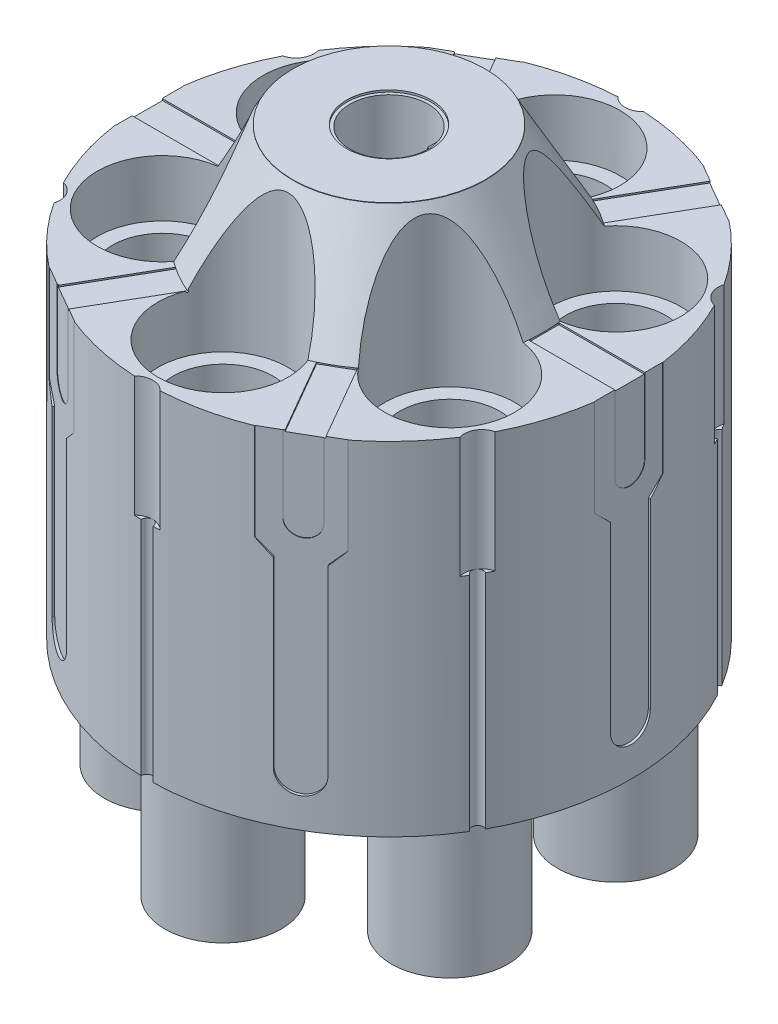
from build123d import *

# Parameters (mm, degrees)
SKETCH2_R            = 30.63
BOSS_EXTRUDE2_DEPTH  = 43.34
SKETCH6_R            = 19.45
BOSS_EXTRUDE6_DEPTH  = 13.09
SKETCH9_R            = 8.239204932
CUT_EXTRUDE1_DEPTH   = 20.25
SKETCH10_R           = 6.33
CUT_EXTRUDE2_DEPTH   = 37.18
SKETCH11_R           = 4.945
CUT_EXTRUDE3_DEPTH   = 35.4
SKETCH12_R           = 2.065
CUT_EXTRUDE4_DEPTH   = 22.03
SKETCH13_R           = 5.347056697
CUT_EXTRUDE5_DEPTH   = 0.25
BOSS_EXTRUDE7_DEPTH  = 34.5
SKETCH16_R           = 29.601532101
SKETCH16_R_2         = 7.36
SKETCH16_R_3         = 4.955
CUT_EXTRUDE9_DEPTH   = 34.5
SKETCH17_R           = 4.955
CUT_EXTRUDE12_DEPTH  = 14.38
SKETCH21_R           = 4.955
SKETCH21_R_2         = 3.15
CUT_EXTRUDE14_DEPTH  = 6.04
CUT_EXTRUDE15_DEPTH  = 0.2
SKETCH24_W           = 1.697473247
SKETCH24_H           = 3.797359521
CUT_EXTRUDE17_DEPTH  = 9.6
CUT_EXTRUDE18_DEPTH  = 0.4
CIRPATTERN1_COUNT    = 6
CUT_EXTRUDE19_DEPTH  = 0.35
CIRPATTERN2_COUNT    = 6
CUT_EXTRUDE23_DEPTH  = 44.3400001
CUT_EXTRUDE24_START  = 43.34
CUT_EXTRUDE24_DEPTH  = 15.26
CIRPATTERN3_COUNT    = 6
CIRPATTERN4_COUNT    = 6
SKETCH31_R           = 7.36
SKETCH31_R_2         = 6.33
BOSS_EXTRUDE10_DEPTH = 17.57


with BuildPart() as part:
    # Sketch2 → Boss-Extrude2 (new body)
    with BuildSketch(Plane(origin=(0, 0, 0), x_dir=(1, 0, 0), z_dir=(0, 1, 0))):
        Circle(SKETCH2_R)
    extrude(amount=BOSS_EXTRUDE2_DEPTH)

    # Sketch6 → Boss-Extrude6 (add)
    with BuildSketch(Plane(origin=(0, 43.34, 0), x_dir=(1, 0, 0), z_dir=(0, 1, 0))):
        Circle(SKETCH6_R)
    extrude(amount=BOSS_EXTRUDE6_DEPTH)

    # Sketch8 → Cut-Revolve5 (revolve, cut)
    with BuildSketch(Plane(origin=(0, 0, 0), x_dir=(0, 0, -1), z_dir=(1, 0, 0))):
        Polygon((19.45, 43.34), (19.45, 56.43), (19.45, 57.490398611), (12.16, 57.490398611), (12.16, 56.378913675), align=None)
    revolve(axis=Axis((0, 43.34, 0), (0, 1, 0)), mode=Mode.SUBTRACT)

    # Sketch9 → Cut-Extrude1 (cut)
    with BuildSketch(Plane(origin=(0, 56.43, 0), x_dir=(1, 0, 0), z_dir=(0, 1, 0))):
        with Locations((0, 20.994816625)):
            Circle(SKETCH9_R)
        with Locations((18.182044545, 10.497408313)):
            Circle(SKETCH9_R)
        with Locations((18.182044545, -10.497408313)):
            Circle(SKETCH9_R)
        with Locations((0, -20.994816625)):
            Circle(SKETCH9_R)
        with Locations((-18.182044545, -10.497408313)):
            Circle(SKETCH9_R)
        with Locations((-18.182044545, 10.497408313)):
            Circle(SKETCH9_R)
    extrude(amount=-CUT_EXTRUDE1_DEPTH, mode=Mode.SUBTRACT)

    # Sketch10 → Cut-Extrude2 (cut, through all)
    with BuildSketch(Plane(origin=(0, 36.18, 0), x_dir=(1, 0, 0), z_dir=(0, 1, 0))):
        with Locations((0, 20.994816625)):
            Circle(SKETCH10_R)
        with Locations((18.182044545, 10.497408313)):
            Circle(SKETCH10_R)
        with Locations((18.182044545, -10.497408313)):
            Circle(SKETCH10_R)
        with Locations((0, -20.994816625)):
            Circle(SKETCH10_R)
        with Locations((-18.182044545, -10.497408313)):
            Circle(SKETCH10_R)
        with Locations((-18.182044545, 10.497408313)):
            Circle(SKETCH10_R)
    extrude(amount=-CUT_EXTRUDE2_DEPTH, mode=Mode.SUBTRACT)

    # Sketch11 → Cut-Extrude3 (cut)
    with BuildSketch(Plane(origin=(0, 56.43, 0), x_dir=(1, 0, 0), z_dir=(0, 1, 0))):
        Circle(SKETCH11_R)
    extrude(amount=-CUT_EXTRUDE3_DEPTH, mode=Mode.SUBTRACT)

    # Sketch12 → Cut-Extrude4 (cut, through all)
    with BuildSketch(Plane(origin=(0, 21.03, 0), x_dir=(1, 0, 0), z_dir=(0, 1, 0))):
        Circle(SKETCH12_R)
    extrude(amount=-CUT_EXTRUDE4_DEPTH, mode=Mode.SUBTRACT)

    # Sketch13 → Cut-Extrude5 (cut)
    with BuildSketch(Plane(origin=(0, 56.43, 0), x_dir=(1, 0, 0), z_dir=(0, 1, 0))):
        Circle(SKETCH13_R)
    extrude(amount=-CUT_EXTRUDE5_DEPTH, mode=Mode.SUBTRACT)

    # Sketch15 → Boss-Extrude7 (add)
    with BuildSketch(Plane(origin=(0, 21.03, 0), x_dir=(1, 0, 0), z_dir=(0, 1, 0))):
        with BuildLine():
            Line((4.0682092, -2.811173937), (4.0682092, -0.81))
            Line((4.0682092, -0.81), (4.8782092, -0.81))
            ThreePointArc((4.8782092, -0.81), (4.583751174, -1.855330205), (4.0682092, -2.811173937))
        make_face()
        with BuildLine():
            Line((4.0682092, 2.811173937), (4.0682092, 0.81))
            Line((4.0682092, 0.81), (4.8782092, 0.81))
            ThreePointArc((4.8782092, 0.81), (4.583751174, 1.855330205), (4.0682092, 2.811173937))
        make_face()
    extrude(amount=BOSS_EXTRUDE7_DEPTH)

    # Sketch16 → Cut-Extrude9 (cut)
    with BuildSketch(Plane.XZ):
        Circle(SKETCH16_R)
        with Locations((-18.182044545, 10.497408313)):
            Circle(SKETCH16_R_2, mode=Mode.SUBTRACT)
        with Locations((0, 20.994816625)):
            Circle(SKETCH16_R_2, mode=Mode.SUBTRACT)
        with Locations((18.182044545, 10.497408313)):
            Circle(SKETCH16_R_2, mode=Mode.SUBTRACT)
        with Locations((18.182044545, -10.497408313)):
            Circle(SKETCH16_R_2, mode=Mode.SUBTRACT)
        with Locations((0, -20.994816625)):
            Circle(SKETCH16_R_2, mode=Mode.SUBTRACT)
        with Locations((-18.182044545, -10.497408313)):
            Circle(SKETCH16_R_2, mode=Mode.SUBTRACT)
        Circle(SKETCH16_R_3, mode=Mode.SUBTRACT)
    extrude(amount=-CUT_EXTRUDE9_DEPTH, mode=Mode.SUBTRACT)

    # Sketch17 → Cut-Extrude12 (cut)
    with BuildSketch(Plane(origin=(0, 0, 0), x_dir=(1, 0, 0), z_dir=(0, 1, 0))):
        Circle(SKETCH17_R)
    extrude(amount=CUT_EXTRUDE12_DEPTH, mode=Mode.SUBTRACT)

    # Sketch21 → Cut-Extrude14 (cut)
    with BuildSketch(Plane.XZ.offset(-14.38)):
        Circle(SKETCH21_R)
        Circle(SKETCH21_R_2, mode=Mode.SUBTRACT)
    extrude(amount=-CUT_EXTRUDE14_DEPTH, mode=Mode.SUBTRACT)

    # Sketch22 → Cut-Extrude15 (cut)
    with BuildSketch(Plane(origin=(0, 43.34, 0), x_dir=(1, 0, 0), z_dir=(0, 1, 0))):
        Polygon((7.938612136, 17.64626892), (16.01292294, 31.63138547), (19.268734276, 29.675897082), (11.227221947, 15.74758916), align=None)
        Polygon((19.408960881, 2.079443487), (19.408960881, -1.717916034), (35.491985537, -1.717916034), (35.55758249, 2.079443487), align=None)
        Polygon((11.662868972, -15.637582634), (8.37425916, -17.536262394), (16.415771488, -31.464570316), (19.737179776, -29.622699184), align=None)
        Polygon((-7.553571683, -17.787783321), (-10.842181495, -15.889103561), (-18.883693823, -29.817411483), (-15.627882487, -31.77289987), align=None)
        Polygon((-19.023920428, -2.220957887), (-19.023920428, 1.576401633), (-35.106945085, 1.576401633), (-35.172542037, -2.220957887), align=None)
        Polygon((-11.277828519, 15.496068233), (-7.989218707, 17.394747994), (-16.030731036, 31.323055916), (-19.352139324, 29.481184783), align=None)
    extrude(amount=-CUT_EXTRUDE15_DEPTH, mode=Mode.SUBTRACT)

    # Sketch24 → Cut-Extrude17 (cut)
    with BuildSketch(Plane(origin=(0, 43.34, 0), x_dir=(1, 0, 0), z_dir=(0, 1, 0))):
        with Locations((31.078736623, 0.180763727)):
            Rectangle(SKETCH24_W, SKETCH24_H)
        Polygon((17.764587509, -26.610281167), (16.915850885, -25.140226213), (13.627241073, -27.038905973), (14.475977697, -28.508960927), align=None)
        Polygon((-14.162885738, -28.689724654), (-13.314149115, -27.2196697), (-16.602758927, -25.32098994), (-17.45149555, -26.791044894), align=None)
        with Locations((-31.078736623, -0.180763727)):
            Rectangle(SKETCH24_W, SKETCH24_H)
        Polygon((-17.764587509, 26.610281167), (-16.915850885, 25.140226213), (-13.627241073, 27.038905973), (-14.475977697, 28.508960927), align=None)
        Polygon((14.162885738, 28.689724654), (13.314149115, 27.2196697), (16.602758927, 25.32098994), (17.45149555, 26.791044894), align=None)
    extrude(amount=-CUT_EXTRUDE17_DEPTH, mode=Mode.SUBTRACT)

    # Sketch26 → Cut-Extrude18 (cut)
    with BuildSketch(Plane(origin=(30.63, 0, 0), x_dir=(0, 0, -1), z_dir=(1, 0, 0))):
        with BuildLine():
            Line((-1.717916034, 33.74), (2.079443487, 33.74))
            ThreePointArc((2.079443487, 33.74), (0.180763726, 31.84132024), (-1.717916034, 33.74))
        make_face()
    cut_extrude18 = extrude(amount=-CUT_EXTRUDE18_DEPTH, mode=Mode.SUBTRACT)

    # CirPattern1: Cut-Extrude18 ×6 about axis
    cirpattern1_axis = Axis((0, 43.34, 0), (0, 1, 0))
    for i in range(1, CIRPATTERN1_COUNT):
        add(cut_extrude18.rotate(cirpattern1_axis, i * 360 / CIRPATTERN1_COUNT), mode=Mode.SUBTRACT)

    # Sketch28 → Cut-Extrude19 (cut)
    with BuildSketch(Plane(origin=(30.63, 0, 0), x_dir=(0, 0, -1), z_dir=(1, 0, 0))):
        with BuildLine():
            Line((-4.315, 44.053563196), (4.315, 44.053563196))
            Line((4.315, 44.053563196), (4.315, 31.142727483))
            Line((4.315, 31.142727483), (2.528620385, 29.356347868))
            Line((2.528620385, 29.356347868), (2.528620385, 6.318897274))
            ThreePointArc((2.528620385, 6.318897274), (0, 3.790276889), (-2.528620385, 6.318897274))
            Line((-2.528620385, 6.318897274), (-2.528620385, 29.356347868))
            Line((-2.528620385, 29.356347868), (-4.315, 31.142727483))
            Line((-4.315, 31.142727483), (-4.315, 44.053563196))
        make_face()
    cut_extrude19 = extrude(amount=-CUT_EXTRUDE19_DEPTH, mode=Mode.SUBTRACT)

    # CirPattern2: Cut-Extrude19 ×6 about axis
    cirpattern2_axis = Axis((0, 0, 0), (0, 1, 0))
    for i in range(1, CIRPATTERN2_COUNT):
        add(cut_extrude19.rotate(cirpattern2_axis, i * 360 / CIRPATTERN2_COUNT), mode=Mode.SUBTRACT)

    # Sketch29 → Cut-Extrude23 (cut, through all)
    with BuildSketch(Plane(origin=(0, 43.34, 0), x_dir=(1, 0, 0), z_dir=(0, 1, 0))):
        with BuildLine():
            Line((-0.74994379, 30.620817826), (-0.74994379, 31.661112378))
            Line((-0.74994379, 31.661112378), (0.74994379, 31.661112378))
            Line((0.74994379, 31.661112378), (0.74994379, 30.620817826))
            ThreePointArc((0.74994379, 30.620817826), (0, 29.88), (-0.74994379, 30.620817826))
        make_face()
    cut_extrude23 = extrude(amount=-CUT_EXTRUDE23_DEPTH, mode=Mode.SUBTRACT)

    # Sketch30 → Cut-Extrude24 (cut)
    with BuildSketch(Plane(origin=(0, 0, 0), x_dir=(1, 0, 0), z_dir=(0, 1, 0)).offset(CUT_EXTRUDE24_START)):
        with BuildLine():
            Line((-1.637565774, 30.586194244), (-1.637565774, 31.749389855))
            Line((-1.637565774, 31.749389855), (1.637565774, 31.749389855))
            Line((1.637565774, 31.749389855), (1.637565774, 30.586194244))
            ThreePointArc((1.637565774, 30.586194244), (0, 29.88), (-1.637565774, 30.586194244))
        make_face()
    cut_extrude24 = extrude(amount=-CUT_EXTRUDE24_DEPTH, mode=Mode.SUBTRACT)

    # CirPattern3: Cut-Extrude24 ×6 about axis
    cirpattern3_axis = Axis((0, 0, 0), (0, 1, 0))
    for i in range(1, CIRPATTERN3_COUNT):
        add(cut_extrude24.rotate(cirpattern3_axis, i * 360 / CIRPATTERN3_COUNT), mode=Mode.SUBTRACT)

    # CirPattern4: Cut-Extrude23 ×6 about axis
    cirpattern4_axis = Axis((0, 0, 0), (0, 1, 0))
    for i in range(1, CIRPATTERN4_COUNT):
        add(cut_extrude23.rotate(cirpattern4_axis, i * 360 / CIRPATTERN4_COUNT), mode=Mode.SUBTRACT)

    # Sketch31 → Boss-Extrude10 (add)
    with BuildSketch(Plane(origin=(0, 0, 0), x_dir=(1, 0, 0), z_dir=(0, 1, 0))):
        with Locations((0, -20.994816625)):
            Circle(SKETCH31_R)
        with Locations((0, -20.994816625)):
            Circle(SKETCH31_R_2, mode=Mode.SUBTRACT)
        with Locations((-18.182044545, -10.497408313)):
            Circle(SKETCH31_R)
        with Locations((-18.182044545, -10.497408313)):
            Circle(SKETCH31_R_2, mode=Mode.SUBTRACT)
        with Locations((-18.182044545, 10.497408313)):
            Circle(SKETCH31_R)
        with Locations((-18.182044545, 10.497408313)):
            Circle(SKETCH31_R_2, mode=Mode.SUBTRACT)
        with Locations((0, 20.994816625)):
            Circle(SKETCH31_R)
        with Locations((0, 20.994816625)):
            Circle(SKETCH31_R_2, mode=Mode.SUBTRACT)
        with Locations((18.182044545, 10.497408313)):
            Circle(SKETCH31_R)
        with Locations((18.182044545, 10.497408313)):
            Circle(SKETCH31_R_2, mode=Mode.SUBTRACT)
        with Locations((18.182044545, -10.497408313)):
            Circle(SKETCH31_R)
        with Locations((18.182044545, -10.497408313)):
            Circle(SKETCH31_R_2, mode=Mode.SUBTRACT)
    extrude(amount=-BOSS_EXTRUDE10_DEPTH)


solid = part.part
